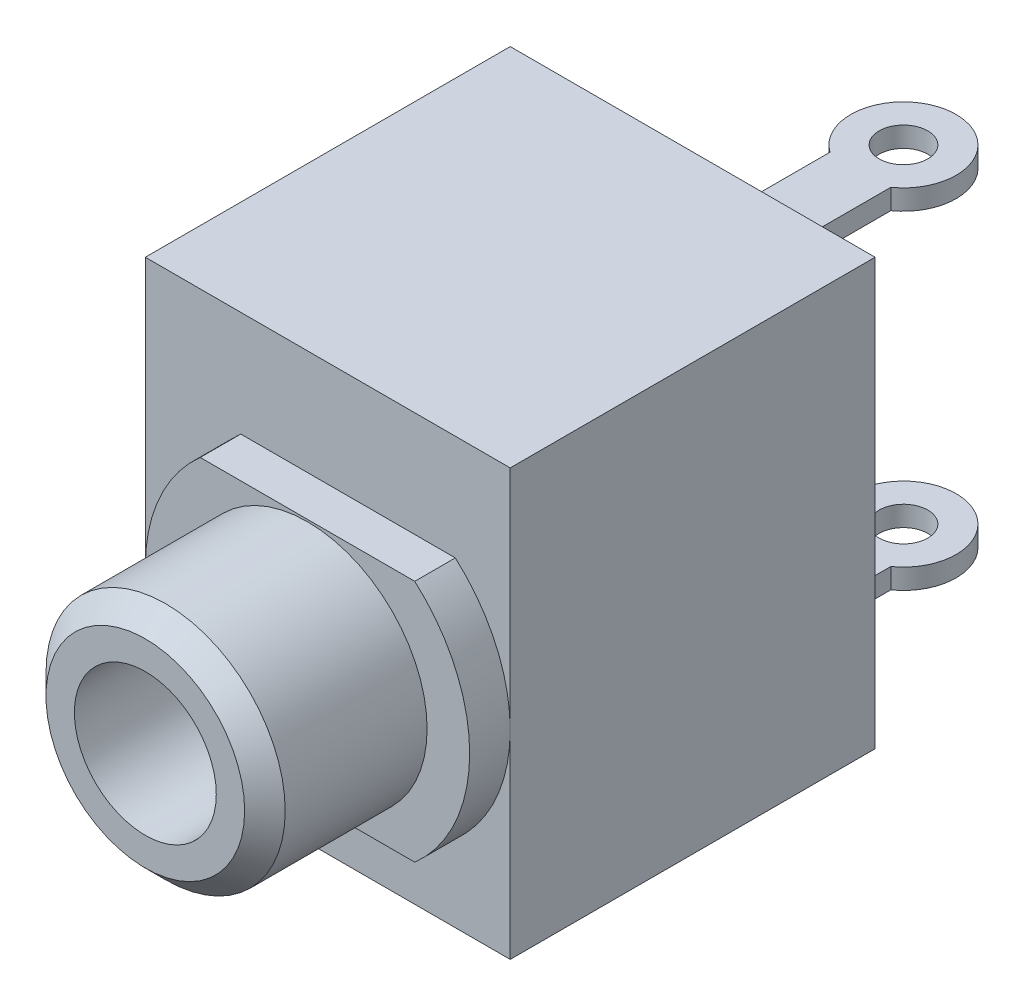
from build123d import *

# Parameters (mm, degrees)
SKETCH3_W           = 9
SKETCH3_H           = 10.5
SKETCH3_W_2         = 1.5
SKETCH3_H_2         = 0.5
SKETCH3_W_3         = 0.5
SKETCH3_H_3         = 1.5
BOSS_EXTRUDE1_DEPTH = 9
SKETCH5_R           = 2.95
BOSS_EXTRUDE4_DEPTH = 1
SKETCH5_3_R         = 2.95
SKETCH5_3_R_2       = 1.75
BOSS_EXTRUDE5_DEPTH = 5
SKETCH3_3_W         = 1.5
SKETCH3_3_H         = 0.5
SKETCH3_3_W_2       = 0.5
SKETCH3_3_H_2       = 1.5
BOSS_EXTRUDE6_DEPTH = 3.7
SKETCH6_R           = 1.3
SKETCH6_R_2         = 0.6
BOSS_EXTRUDE7_DEPTH = 0.5
CUT_EXTRUDE1_DEPTH  = 3.7
CUT_EXTRUDE2_DEPTH  = 3.7
SKETCH7_3_R         = 1.3
SKETCH7_3_R_2       = 0.6
BOSS_EXTRUDE8_DEPTH = 0.5
CUT_EXTRUDE3_DEPTH  = 3.7
SKETCH8_3_R         = 1.3
SKETCH8_3_R_2       = 0.6
BOSS_EXTRUDE9_DEPTH = 0.5
CHAMFER1_SIZE       = 0.5


with BuildPart() as part:
    # Sketch3 → Boss-Extrude1 (new body)
    with BuildSketch(Plane.XY):
        with Locations((-0.5, 0.35)):
            Rectangle(SKETCH3_W, SKETCH3_H)
        with Locations((1, -3.7)):
            Rectangle(SKETCH3_W_2, SKETCH3_H_2, mode=Mode.SUBTRACT)
        with Locations((-3.8, -1.4)):
            Rectangle(SKETCH3_W_3, SKETCH3_H_3, mode=Mode.SUBTRACT)
        with Locations((1, 4.4)):
            Rectangle(SKETCH3_W_2, SKETCH3_H_2, mode=Mode.SUBTRACT)
        with Locations((1, -3.7)):
            Rectangle(SKETCH3_W_2, SKETCH3_H_2)
        with Locations((-3.8, -1.4)):
            Rectangle(SKETCH3_W_3, SKETCH3_H_3)
        with Locations((1, 4.4)):
            Rectangle(SKETCH3_W_2, SKETCH3_H_2)
    extrude(amount=BOSS_EXTRUDE1_DEPTH)

    # Sketch5 → Boss-Extrude4 (add)
    with BuildSketch(Plane.XY.offset(9)):
        with BuildLine():
            ThreePointArc((-4, 0), (-3.645751311, -1.645751311), (-2.645751311, -3))
            Line((-2.645751311, -3), (2.645751311, -3))
            ThreePointArc((2.645751311, -3), (3.645751311, -1.645751311), (4, 0))
            ThreePointArc((4, 0), (3.645751311, 1.645751311), (2.645751311, 3))
            Line((2.645751311, 3), (-2.645751311, 3))
            ThreePointArc((-2.645751311, 3), (-3.645751311, 1.645751311), (-4, 0))
        make_face()
        Circle(SKETCH5_R, mode=Mode.SUBTRACT)
    extrude(amount=BOSS_EXTRUDE4_DEPTH)

    # Sketch5_3 → Boss-Extrude5 (add)
    with BuildSketch(Plane.XY.offset(9)):
        Circle(SKETCH5_3_R)
        Circle(SKETCH5_3_R_2, mode=Mode.SUBTRACT)
    extrude(amount=BOSS_EXTRUDE5_DEPTH)

    # Sketch3_3 → Boss-Extrude6 (add)
    with BuildSketch(Plane.XY):
        with Locations((1, -3.7)):
            Rectangle(SKETCH3_3_W, SKETCH3_3_H)
        with Locations((-3.8, -1.4)):
            Rectangle(SKETCH3_3_W_2, SKETCH3_3_H_2)
        with Locations((1, 4.4)):
            Rectangle(SKETCH3_3_W, SKETCH3_3_H)
    extrude(amount=-BOSS_EXTRUDE6_DEPTH)

    # Sketch6 → Boss-Extrude7 (add)
    with BuildSketch(Plane.XZ.offset(3.95)):
        with Locations((1, -3.7)):
            Circle(SKETCH6_R)
        with Locations((1, -3.7)):
            Circle(SKETCH6_R_2, mode=Mode.SUBTRACT)
    extrude(amount=-BOSS_EXTRUDE7_DEPTH)

    # Sketch6_2 → Cut-Extrude1 (cut)
    with BuildSketch(Plane.XZ.offset(3.95)):
        with BuildLine():
            Line((0.4, -3.7), (1.6, -3.7))
            ThreePointArc((1.6, -3.7), (1, -3.1), (0.4, -3.7))
        make_face()
        with BuildLine():
            ThreePointArc((0.4, -3.7), (1, -4.3), (1.6, -3.7))
            Line((1.6, -3.7), (0.4, -3.7))
        make_face()
    extrude(amount=-CUT_EXTRUDE1_DEPTH, mode=Mode.SUBTRACT)

    # Sketch7 → Cut-Extrude2 (cut)
    with BuildSketch(Plane.XZ.offset(-4.15)):
        with BuildLine():
            Line((0.4, -3.7), (1.6, -3.7))
            ThreePointArc((1.6, -3.7), (1, -3.1), (0.4, -3.7))
        make_face()
        with BuildLine():
            ThreePointArc((0.4, -3.7), (1, -4.3), (1.6, -3.7))
            Line((1.6, -3.7), (0.4, -3.7))
        make_face()
    extrude(amount=-CUT_EXTRUDE2_DEPTH, mode=Mode.SUBTRACT)

    # Sketch7_3 → Boss-Extrude8 (add)
    with BuildSketch(Plane.XZ.offset(-4.15)):
        with Locations((1, -3.7)):
            Circle(SKETCH7_3_R)
        with Locations(Location((1, -3.7, 0), (0, 0, 270))):
            Circle(SKETCH7_3_R_2, mode=Mode.SUBTRACT)
    extrude(amount=-BOSS_EXTRUDE8_DEPTH)

    # Sketch8 → Cut-Extrude3 (cut)
    with BuildSketch(Plane.ZY.offset(4.05)):
        with BuildLine():
            ThreePointArc((-3.7, -2), (-3.275735931, -1.824264069), (-3.1, -1.4))
            ThreePointArc((-3.1, -1.4), (-3.275735931, -0.975735931), (-3.7, -0.8))
            Line((-3.7, -0.8), (-3.7, -2))
        make_face()
        with BuildLine():
            Line((-3.7, -2), (-3.7, -0.8))
            ThreePointArc((-3.7, -0.8), (-4.3, -1.4), (-3.7, -2))
        make_face()
    extrude(amount=-CUT_EXTRUDE3_DEPTH, mode=Mode.SUBTRACT)

    # Sketch8_3 → Boss-Extrude9 (add)
    with BuildSketch(Plane.ZY.offset(4.05)):
        with Locations((-3.7, -1.4)):
            Circle(SKETCH8_3_R)
        with Locations((-3.7, -1.4)):
            Circle(SKETCH8_3_R_2, mode=Mode.SUBTRACT)
    extrude(amount=-BOSS_EXTRUDE9_DEPTH)

    # Chamfer1
    chamfer1_edges = [part.edges().sort_by_distance(p)[0] for p in [
        (-2.95, 0, 14),
    ]]
    chamfer(chamfer1_edges, length=CHAMFER1_SIZE)


solid = part.part
